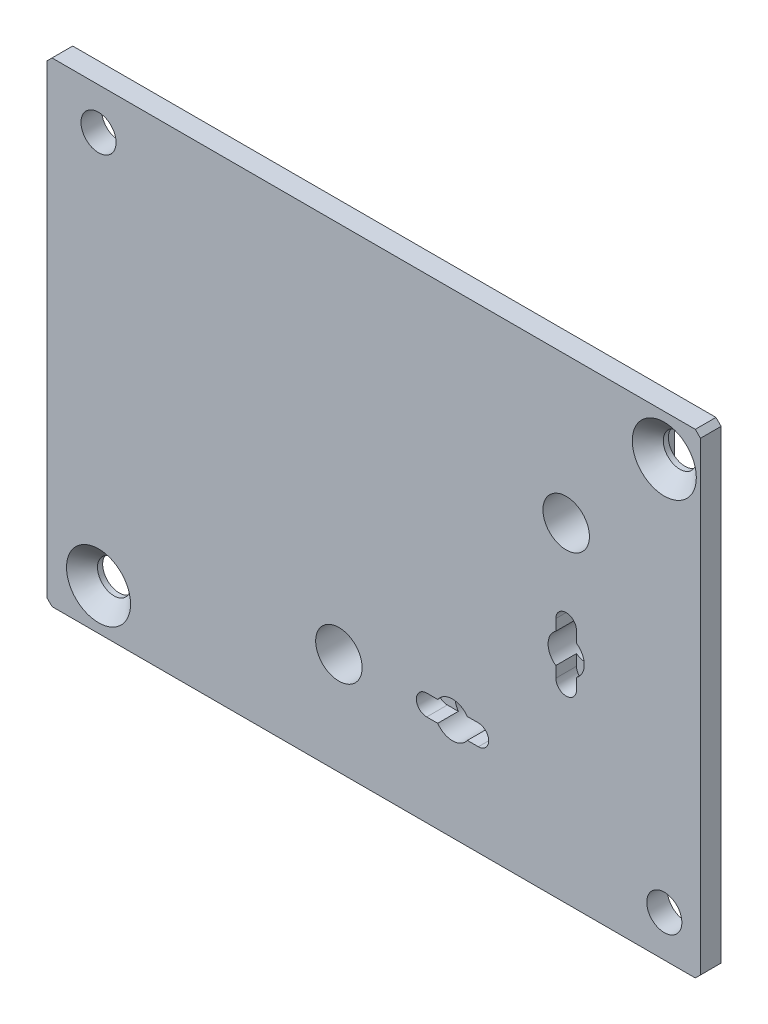
from build123d import *

# Parameters (mm, degrees)
SKICA1_W                                  = 49.2698
SKICA1_H                                  = 40
P_IDAT_VYSUNUT_M1_DEPTH                   = 2
ZKOSEN_1_SIZE                             = 0.5
SKICA4_W                                  = 63.2698
SKICA4_H                                  = 46
P_IDAT_VYSUNUT_M2_DEPTH                   = 2
KU_ELOV_ZAHLOUBEN_PRO_M3_ROUBU_SE_2_COUNT = 2
KU_ELOV_ZAHLOUBEN_PRO_M3_ROUBU_SE_2_PITCH = 66.661315559
F_3_4_3_4_PR_M_R_D_RY1_D                  = 3.4
F_3_4_3_4_PR_M_R_D_RY1_DEPTH              = 2
ODEBRAT_VYSUNUT_M1_DEPTH                  = 2
F_3_5_3_5_PR_M_R_D_RY1_D                  = 3.5
F_3_5_3_5_PR_M_R_D_RY1_DEPTH              = 4
F_4_5_4_5_PR_M_R_D_RY1_D                  = 4.5
F_4_5_4_5_PR_M_R_D_RY1_DEPTH              = 4
ZKOSEN_2_SIZE                             = 0.5


with BuildPart() as part:
    # Skica1 → Přidat vysunutím1 (new body)
    with BuildSketch(Plane.XY):
        with Locations((-294.244757855, 0)):
            Rectangle(SKICA1_W, SKICA1_H)
    extrude(amount=-P_IDAT_VYSUNUT_M1_DEPTH)

    # Zkosení1
    zkosen_1_edges = [part.edges().sort_by_distance(p)[0] for p in [
        (-269.609857855, 0, -2),
        (-294.244757855, 20, -2),
        (-318.879657855, 0, -2),
        (-294.244757855, -20, -2),
    ]]
    chamfer(zkosen_1_edges, length=ZKOSEN_1_SIZE)

    # Skica3 → Odebrat rotací2 (revolve, cut)
    with BuildSketch(Plane(origin=(0, -13.1125, 0), x_dir=(-1, 0, 0), z_dir=(0, -1, 0))):
        Polygon((273.341908662, 2), (276.609857855, 0.113248654), (276.609857855, 2), align=None)
    revolve(axis=Axis((-276.609857855, -13.1125, -0.113248654), (0, 0, -1)), mode=Mode.SUBTRACT)

    # Skica4 → Přidat vysunutím2 (add)
    with BuildSketch(Plane.XY):
        with Locations((-295.244757855, 0)):
            Rectangle(SKICA4_W, SKICA4_H)
    extrude(amount=P_IDAT_VYSUNUT_M2_DEPTH)

    # Skica7 → Kuželové zahloubení pro M3 šroubu se zápustnou hlavou plochou1 (revolve, cut)
    with BuildSketch(Plane(origin=(-321.879657855, -19, 2), x_dir=(0, -1, 0), z_dir=(1, 0, 0))):
        Polygon((0, 0), (0, 2), (1.6, 2), (1.6, 1.5), (3.1, 0), align=None)
    ku_elov_zahlouben_pro_m3_roubu_se_z_p = revolve(axis=Axis((-321.879657855, -19, 8.35), (0, 0, -1)), mode=Mode.SUBTRACT)

    # Ku_elov_ zahlouben_ pro M3 _roubu se 2: Kuželové zahloubení pro M3 šroubu se zápustnou hlavou plochou1 ×2
    with Locations(*[Vector(0.821612948, 0.570045756, 0) * (i * KU_ELOV_ZAHLOUBEN_PRO_M3_ROUBU_SE_2_PITCH) for i in range(1, KU_ELOV_ZAHLOUBEN_PRO_M3_ROUBU_SE_2_COUNT)]):
        add(ku_elov_zahlouben_pro_m3_roubu_se_z_p, mode=Mode.SUBTRACT)

    # Ø3.4 (3.4) průměr díry1
    with Locations(Plane(origin=(-267.109857855, -19, 2), x_dir=(1, 0, 0), z_dir=(0, 0, 1))):
        with Locations((0, 0), (-54.7698, 38)):
            Hole(F_3_4_3_4_PR_M_R_D_RY1_D / 2, depth=F_3_4_3_4_PR_M_R_D_RY1_DEPTH)

    # Skica9 → Odebrat vysunutím1 (cut)
    with BuildSketch(Plane.XY.offset(2)):
        with BuildLine():
            Line((-290.109857855, -14.1125), (-285.109857855, -14.1125))
            ThreePointArc((-285.109857855, -14.1125), (-284.109857855, -13.1125), (-285.109857855, -12.1125))
            Line((-285.109857855, -12.1125), (-290.109857855, -12.1125))
            ThreePointArc((-290.109857855, -12.1125), (-291.109857855, -13.1125), (-290.109857855, -14.1125))
        make_face()
        with BuildLine():
            Line((-277.609857855, 0.3875), (-277.609857855, -4.6125))
            ThreePointArc((-277.609857855, -4.6125), (-276.609857855, -5.6125), (-275.609857855, -4.6125))
            Line((-275.609857855, -4.6125), (-275.609857855, 0.3875))
            ThreePointArc((-275.609857855, 0.3875), (-276.609857855, 1.3875), (-277.609857855, 0.3875))
        make_face()
    extrude(amount=-ODEBRAT_VYSUNUT_M1_DEPTH, mode=Mode.SUBTRACT)

    # Ø3.5 (3.5) průměr díry1
    with Locations(Plane(origin=(-287.609857855, -13.1125, 2), x_dir=(1, 0, 0), z_dir=(0, 0, 1))):
        with Locations((0, 0), (11, 11)):
            Hole(F_3_5_3_5_PR_M_R_D_RY1_D / 2, depth=F_3_5_3_5_PR_M_R_D_RY1_DEPTH)

    # Ø4.5 (4.5) průměr díry1
    with Locations(Plane(origin=(-276.609857855, 8.8875, 2), x_dir=(1, 0, 0), z_dir=(0, 0, 1))):
        with Locations((0, 0), (-22, -22)):
            Hole(F_4_5_4_5_PR_M_R_D_RY1_D / 2, depth=F_4_5_4_5_PR_M_R_D_RY1_DEPTH)

    # Zkosení2
    zkosen_2_edges = [part.edges().sort_by_distance(p)[0] for p in [
        (-263.609857855, -23, 1),
        (-263.609857855, 23, 1),
        (-326.879657855, 23, 1),
        (-326.879657855, -23, 1),
    ]]
    chamfer(zkosen_2_edges, length=ZKOSEN_2_SIZE)


solid = part.part
